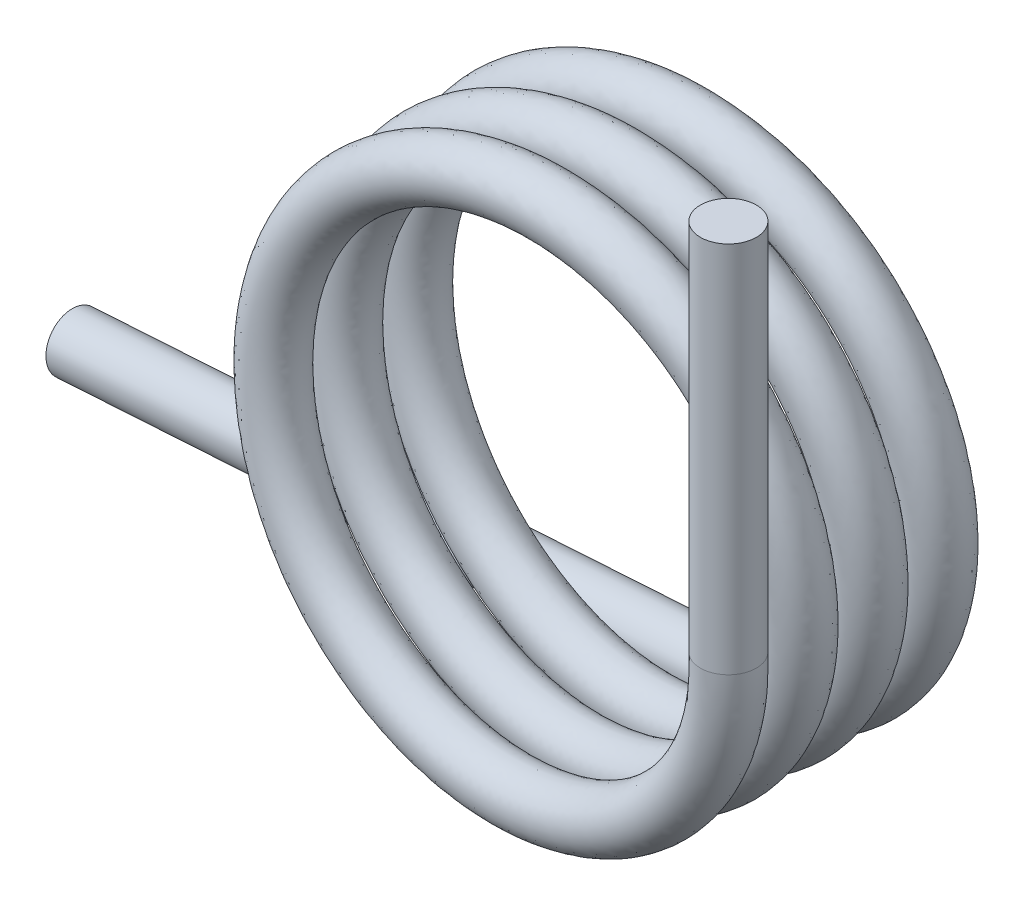
from build123d import *

# Parameters (mm, degrees)
SWEEP1_PITCH        = 0.75
SWEEP1_HEIGHT       = 2.43
SWEEP1_RADIUS       = 2.625
SWEEP1_START_ANGLE  = 180
SKETCH2_R           = 0.3
SKETCH4_R           = 0.3
BOSS_EXTRUDE1_DEPTH = 7
SKETCH5_R           = 0.3
BOSS_EXTRUDE2_DEPTH = 4


with BuildPart() as part:
    # Sweep1: sweep along a helix
    with BuildLine() as sweep1_path:
        add(Helix(SWEEP1_PITCH, SWEEP1_HEIGHT, SWEEP1_RADIUS, center=(0, 0, 0), direction=(0, 0, -1), mode=Mode.PRIVATE).rotate(Axis((0, 0, 0), (0, 0, -1)), SWEEP1_START_ANGLE))
    # Sketch2 → Sweep1 (sweep)
    with BuildSketch(Plane(origin=(0, 0, 0), x_dir=(1, 0, 0), z_dir=(0, 1, 0))):
        with Locations((2.625, 0)):
            Circle(SKETCH2_R)
    sweep(path=sweep1_path.line, is_frenet=True)

    # Sketch4 → Boss-Extrude1 (add)
    with BuildSketch(Plane(origin=(0, 0, 0), x_dir=(0.062795574, -0.99802641, 0), z_dir=(-0.99802641, -0.062795574, 0))):
        with Locations((2.625, -2.430301148)):
            Circle(SKETCH4_R)
    extrude(amount=BOSS_EXTRUDE1_DEPTH)

    # Sketch5 → Boss-Extrude2 (add)
    with BuildSketch(Plane(origin=(0, 0, 0), x_dir=(1, 0, 0), z_dir=(0, 1, 0))):
        with Locations((2.625, 0)):
            Circle(SKETCH5_R)
    extrude(amount=BOSS_EXTRUDE2_DEPTH)


solid = part.part
